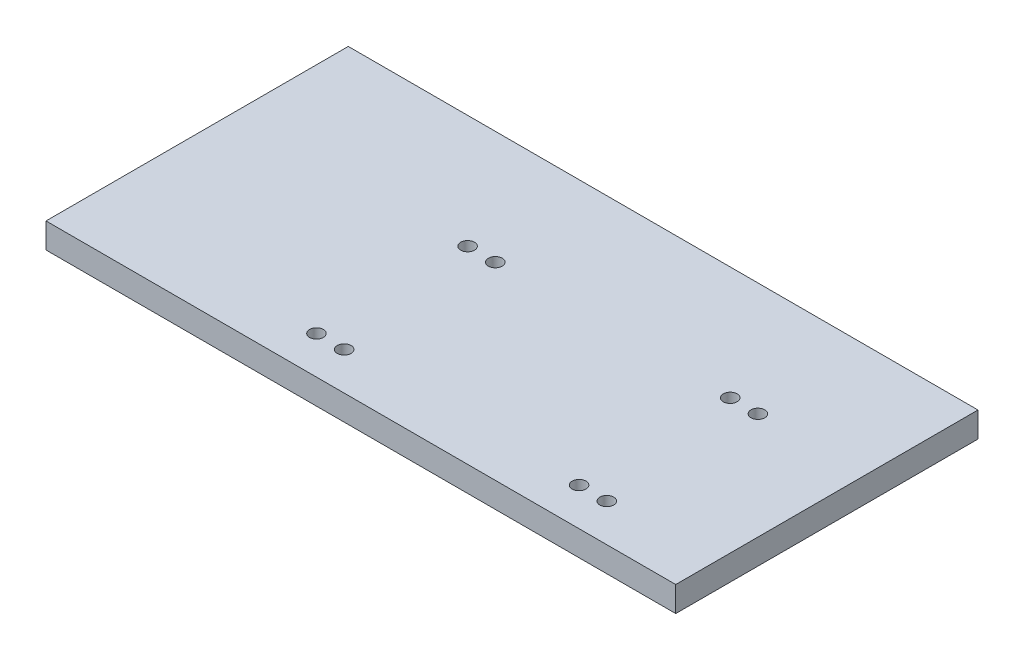
from build123d import *

# Parameters (mm, degrees)
SKETCH1_W            = 250
SKETCH1_H            = 120
BOSS_EXTRUDE1_DEPTH  = 10
M5_CLEARANCE_HOLE1_D = 5.5
CUT_EXTRUDE1_DEPTH   = 5


with BuildPart() as part:
    # Sketch1 → Boss-Extrude1 (new body)
    with BuildSketch(Plane(origin=(0, 0, 0), x_dir=(1, 0, 0), z_dir=(0, 1, 0))):
        with Locations((125, 60)):
            Rectangle(SKETCH1_W, SKETCH1_H)
    extrude(amount=BOSS_EXTRUDE1_DEPTH)

    # M5 Clearance Hole1 (through all)
    with Locations(Plane(origin=(0, 10, 0), x_dir=(1, 0, 0), z_dir=(0, 1, 0))):
        with Locations((196.625581146, 15), (207.625581146, 15), (207.625581146, 75), (196.625581146, 75)):
            m5_clearance_hole1 = Hole(M5_CLEARANCE_HOLE1_D / 2)

    # Sketch5 → Cut-Extrude1 (cut)
    with BuildSketch(Plane(origin=(0, 0, 0), x_dir=(-1, 0, 0), z_dir=(0, -1, 0))):
        with BuildLine():
            Line((-196.625581146, 8.75), (-207.625581146, 8.75))
            ThreePointArc((-207.625581146, 8.75), (-213.875581146, 15), (-207.625581146, 21.25))
            Line((-207.625581146, 21.25), (-196.625581146, 21.25))
            ThreePointArc((-196.625581146, 21.25), (-190.375581146, 15), (-196.625581146, 8.75))
        make_face()
        with BuildLine():
            Line((-196.625581146, 68.75), (-207.625581146, 68.75))
            ThreePointArc((-207.625581146, 68.75), (-213.875581146, 75), (-207.625581146, 81.25))
            Line((-207.625581146, 81.25), (-196.625581146, 81.25))
            ThreePointArc((-196.625581146, 81.25), (-190.375581146, 75), (-196.625581146, 68.75))
        make_face()
    cut_extrude1 = extrude(amount=-CUT_EXTRUDE1_DEPTH, mode=Mode.SUBTRACT)

    # Mirror1: M5 Clearance Hole1, Cut-Extrude1 across plane
    add(m5_clearance_hole1.mirror(Plane(origin=(150, 0, 0), x_dir=(0, 0, 1), z_dir=(1, 0, 0))), mode=Mode.SUBTRACT)
    add(cut_extrude1.mirror(Plane(origin=(150, 0, 0), x_dir=(0, 0, 1), z_dir=(1, 0, 0))), mode=Mode.SUBTRACT)


solid = part.part
